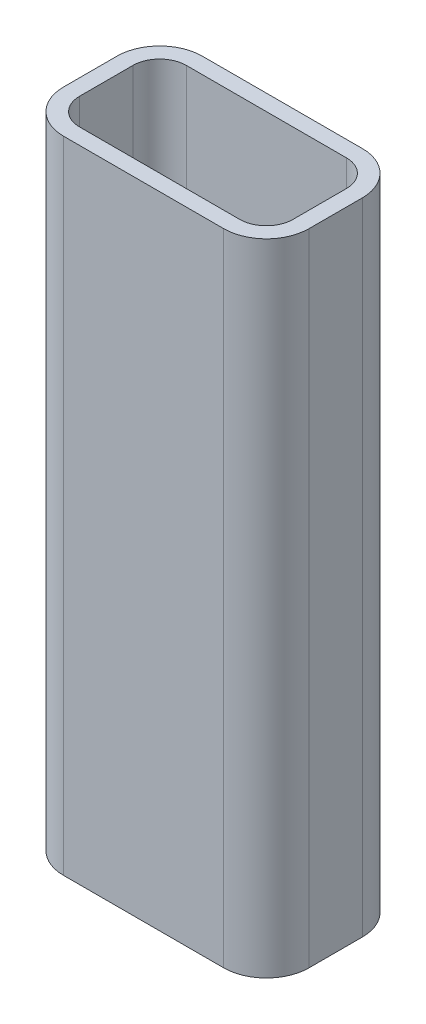
from build123d import *

# Parameters (mm, degrees)
EXTRUDE_THIN1_DEPTH = 120


with BuildPart() as part:
    # Sketch1 → Extrude-Thin1 (new body)
    with BuildSketch(Plane(origin=(0, 0, 0), x_dir=(1, 0, 0), z_dir=(0, 1, 0))):
        with BuildLine():
            Line((23, 5), (23, -5))
            ThreePointArc((23, -5), (20.656854249, -10.656854249), (15, -13))
            Line((15, -13), (-15, -13))
            ThreePointArc((-15, -13), (-20.656854249, -10.656854249), (-23, -5))
            Line((-23, -5), (-23, 5))
            ThreePointArc((-23, 5), (-20.656854249, 10.656854249), (-15, 13))
            Line((-15, 13), (15, 13))
            ThreePointArc((15, 13), (20.656854249, 10.656854249), (23, 5))
        make_face()
        with BuildLine():
            Line((20, 5), (20, -5))
            ThreePointArc((20, -5), (18.535533906, -8.535533906), (15, -10))
            Line((15, -10), (-15, -10))
            ThreePointArc((-15, -10), (-18.535533906, -8.535533906), (-20, -5))
            Line((-20, -5), (-20, 5))
            ThreePointArc((-20, 5), (-18.535533906, 8.535533906), (-15, 10))
            Line((-15, 10), (15, 10))
            ThreePointArc((15, 10), (18.535533906, 8.535533906), (20, 5))
        make_face(mode=Mode.SUBTRACT)
    extrude(amount=EXTRUDE_THIN1_DEPTH)


solid = part.part
